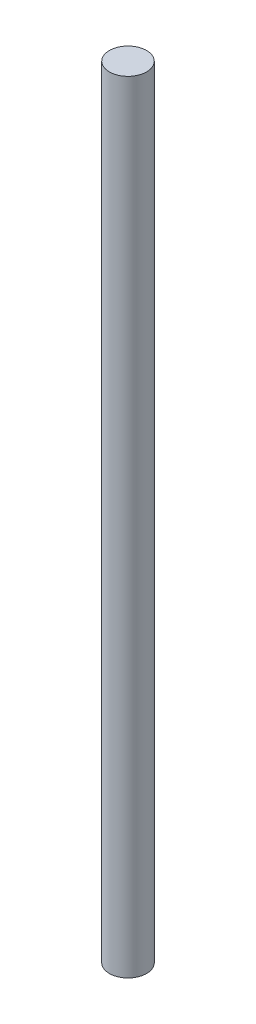
from build123d import *

# Parameters (mm, degrees)
CROQUIS1_R              = 4
SALIENTE_EXTRUIR1_DEPTH = 168


with BuildPart() as part:
    # Croquis1 → Saliente-Extruir1 (new body)
    with BuildSketch(Plane(origin=(0, 0, 0), x_dir=(1, 0, 0), z_dir=(0, 1, 0))):
        Circle(CROQUIS1_R)
    extrude(amount=SALIENTE_EXTRUIR1_DEPTH)


solid = part.part
